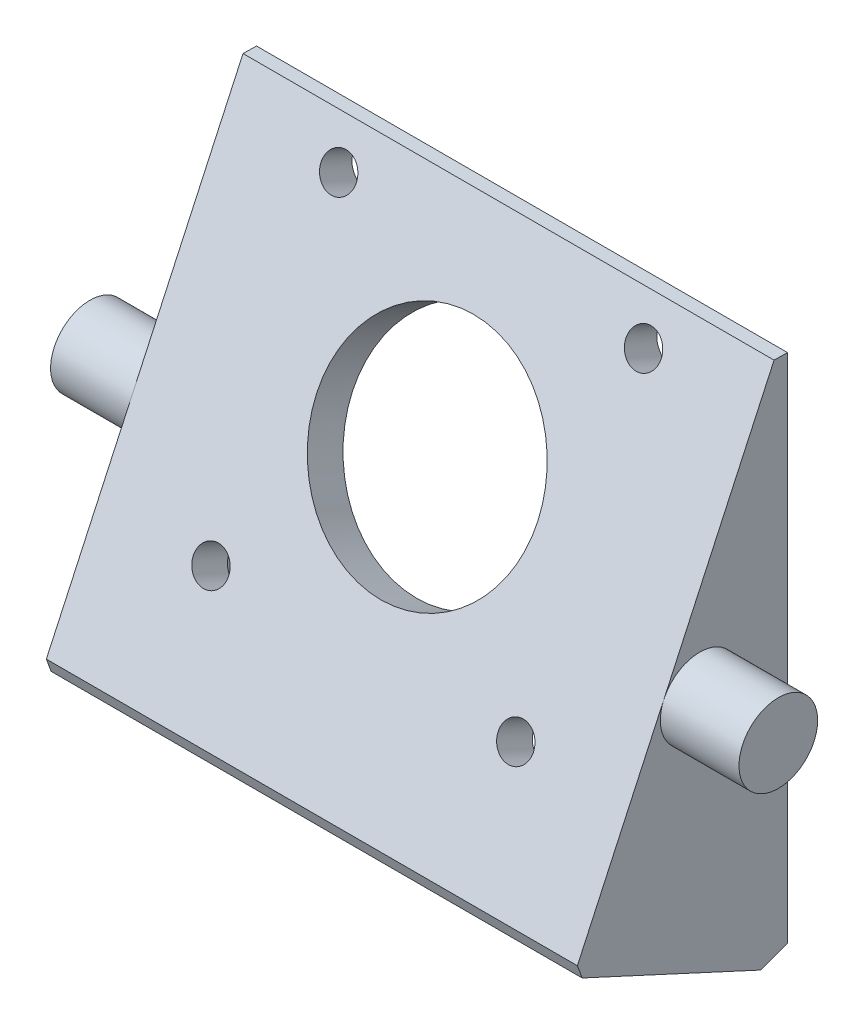
from build123d import *

# Parameters (mm, degrees)
SALIENTE_EXTRUIR1_DEPTH = 27
VACIADO1_T              = -4
NEMA_REACH              = 25.785
CROQUIS2_R              = 11.25
CROQUIS2_R_2            = 1.8
CHAFL_N1_SIZE           = 1
CHAFL_N2_SIZE           = 3
CHAFL_N2_SIZE2          = 3.277706745
CHAFL_N3_SIZE2          = 3
CHAFL_N3_SIZE           = 2.260708589
REDONDEO1_R             = 2
CROQUIS6_R              = 4
EJE_DEPTH               = 8


with BuildPart() as part:
    # Croquis1 → Saliente-Extruir1 (new body, symmetric)
    with BuildSketch(Plane(origin=(0, 0, 0), x_dir=(0, 0, -1), z_dir=(1, 0, 0))):
        Polygon((0, 28.635642127), (0, -28.635642127), (-21.791025228, -18.578245867), align=None)
    extrude(amount=SALIENTE_EXTRUIR1_DEPTH, both=True)

    # Vaciado1
    vaciado1_openings = [part.faces().sort_by_distance(p)[0] for p in [
        (0, 0, 0),
    ]]
    offset(amount=VACIADO1_T, openings=vaciado1_openings, kind=Kind.INTERSECTION)

    # Croquis2 → NEMA (cut, up to next)
    with BuildSketch(Plane(origin=(0, 3.35246542, 7.263675076), x_dir=(1, 0, 0), z_dir=(0, -0.419058177, -0.907959385)), mode=Mode.PRIVATE) as nema_sk1:
        with Locations((0, -3)):
            Circle(CROQUIS2_R)
    nema_tool1 = extrude(nema_sk1.sketch, amount=-NEMA_REACH, mode=Mode.PRIVATE) & part.part
    add(nema_tool1.solids().sort_by_distance((0, 6.076344, 6.006501))[0], mode=Mode.SUBTRACT)
    # Croquis2 → NEMA (cut, up to next)
    with BuildSketch(Plane(origin=(0, 3.35246542, 7.263675076), x_dir=(1, 0, 0), z_dir=(0, -0.419058177, -0.907959385)), mode=Mode.PRIVATE) as nema_sk2:
        with Locations((15.5, -18.5)):
            Circle(CROQUIS2_R_2)
    nema_tool2 = extrude(nema_sk2.sketch, amount=-NEMA_REACH, mode=Mode.PRIVATE) & part.part
    add(nema_tool2.solids().sort_by_distance((15.5, 20.149714, -0.488901))[0], mode=Mode.SUBTRACT)
    # Croquis2 → NEMA (cut, up to next)
    with BuildSketch(Plane(origin=(0, 3.35246542, 7.263675076), x_dir=(1, 0, 0), z_dir=(0, -0.419058177, -0.907959385)), mode=Mode.PRIVATE) as nema_sk3:
        with Locations((-15.5, -18.5)):
            Circle(CROQUIS2_R_2)
    nema_tool3 = extrude(nema_sk3.sketch, amount=-NEMA_REACH, mode=Mode.PRIVATE) & part.part
    add(nema_tool3.solids().sort_by_distance((-15.5, 20.149714, -0.488901))[0], mode=Mode.SUBTRACT)
    # Croquis2 → NEMA (cut, up to next)
    with BuildSketch(Plane(origin=(0, 3.35246542, 7.263675076), x_dir=(1, 0, 0), z_dir=(0, -0.419058177, -0.907959385)), mode=Mode.PRIVATE) as nema_sk4:
        with Locations((-15.5, 12.5)):
            Circle(CROQUIS2_R_2)
    nema_tool4 = extrude(nema_sk4.sketch, amount=-NEMA_REACH, mode=Mode.PRIVATE) & part.part
    add(nema_tool4.solids().sort_by_distance((-15.5, -7.997027, 12.501902))[0], mode=Mode.SUBTRACT)
    # Croquis2 → NEMA (cut, up to next)
    with BuildSketch(Plane(origin=(0, 3.35246542, 7.263675076), x_dir=(1, 0, 0), z_dir=(0, -0.419058177, -0.907959385)), mode=Mode.PRIVATE) as nema_sk5:
        with Locations((15.5, 12.5)):
            Circle(CROQUIS2_R_2)
    nema_tool5 = extrude(nema_sk5.sketch, amount=-NEMA_REACH, mode=Mode.PRIVATE) & part.part
    add(nema_tool5.solids().sort_by_distance((15.5, -7.997027, 12.501902))[0], mode=Mode.SUBTRACT)

    # Chaflán1
    chafl_n1_edges = [part.edges().sort_by_distance(p)[0] for p in [
        (0, -18.578245867, 21.791025228),
    ]]
    chamfer(chafl_n1_edges, length=CHAFL_N1_SIZE)

    # Chaflán2
    chafl_n2_edges = [part.edges().sort_by_distance(p)[0] for p in [
        (0, 28.635642127, 0),
    ]]
    chafl_n2_side = [part.faces().sort_by_distance(p)[0] for p in [
        (0, 27.84849538, 0),
    ]]
    chamfer(chafl_n2_edges, length=CHAFL_N2_SIZE, length2=CHAFL_N2_SIZE2, reference=chafl_n2_side[0])

    # Chaflán3
    chafl_n3_edges = [part.edges().sort_by_distance(p)[0] for p in [
        (0, -28.635642127, 0),
    ]]
    chamfer(chafl_n3_edges, length=CHAFL_N3_SIZE, length2=CHAFL_N3_SIZE2)

    # Redondeo1
    redondeo1_edges = [part.edges().sort_by_distance(p)[0] for p in [
        (-23, 1.233893523, 8.24147749),
        (-23, -20.426399881, 8.24147749),
        (0, -16.622641039, 16.48295498),
        (23, 1.233893523, 8.24147749),
        (23, -20.426399881, 8.24147749),
    ]]
    fillet(redondeo1_edges, radius=REDONDEO1_R)

    # Croquis6 → EJE (add)
    with BuildSketch(Plane(origin=(27, 0, 0), x_dir=(0, 0, -1), z_dir=(1, 0, 0))):
        with Locations((-8.939907786, -0.279372118)):
            Circle(CROQUIS6_R)
    eje = extrude(amount=EJE_DEPTH)

    # Simetría1: EJE across plane
    add(eje.mirror(Plane(origin=(0, 0, 0), x_dir=(0, 0, 1), z_dir=(1, 0, 0))))


solid = part.part
